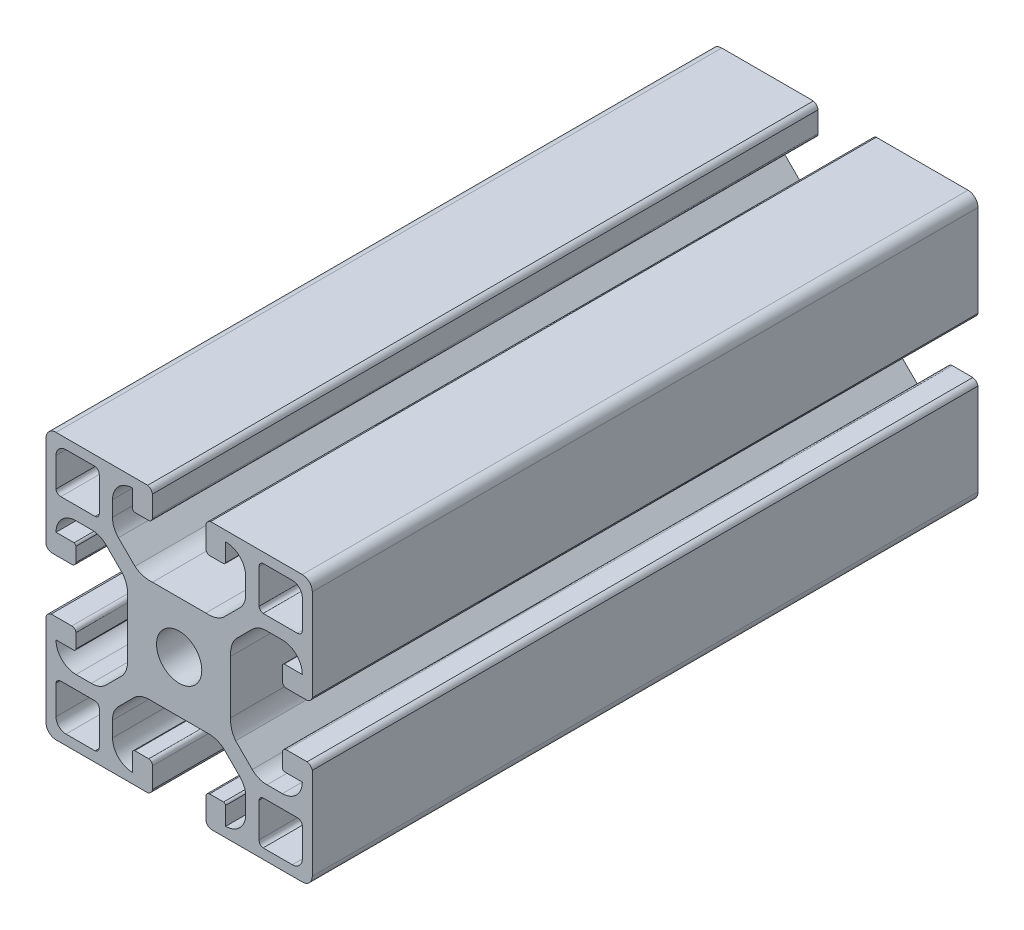
from build123d import *

# Parameters (mm, degrees)
CROQUIS1_R              = 3.4
SALIENTE_EXTRUIR1_DEPTH = 100


with BuildPart() as part:
    # Croquis1 → Saliente-Extruir1 (new body)
    with BuildSketch(Plane.XY):
        with BuildLine():
            ThreePointArc((1.5, 20), (0.439339828, 19.560660172), (0, 18.5))
            Line((0, 18.5), (0, 4.723246277))
            add(Edge.make_bspline(
                [(0, 4.723246277), (0.16818163, 4.15421854), (0.776519027, 4)],
                knots=[0, 0, 0, 1, 1, 1], degree=2))
            Line((0.776519027, 4), (3.876499959, 4))
            add(Edge.make_bspline(
                [(3.876499959, 4), (4.428343851, 4.075321958), (4.5, 4.561581647)],
                knots=[0, 0, 0, 0.770148696, 0.770148696, 0.770148696], degree=2))
            Line((4.5, 4.561581647), (4.5, 4.888433939))
            Line((4.5, 4.888433939), (4.5, 6.675480873))
            add(Edge.make_bspline(
                [(4.226708403, 7), (4.442584391, 6.908044465), (4.5, 6.675480873)],
                knots=[0, 0, 0, 1, 1, 1], degree=2))
            Line((4.226708403, 7), (1.5, 7))
            ThreePointArc((1.5, 7), (2.378679656, 9.121320344), (4.5, 10))
            Line((4.5, 10), (6.795713853, 10))
            add(Edge.make_bspline(
                [(6.795713853, 10), (6.864922078, 10.001348654), (6.933119616, 10)],
                knots=[0, 0, 0, 0.053884422, 0.053884422, 0.053884422], degree=2))
            add(Edge.make_bspline(
                [(6.933119616, 10), (8.130548293, 9.976320018), (9.016390221, 9.121082451)],
                knots=[0.053884422, 0.053884422, 0.053884422, 1, 1, 1], degree=2))
            Line((9.016390221, 9.121082451), (11.507582012, 6.629890661))
            add(Edge.make_bspline(
                [(11.507582012, 6.629890661), (12.156952743, 5.772287934), (12.25, 4.723246277)],
                knots=[0, 0, 0, 0.74933997, 0.74933997, 0.74933997], degree=2))
            add(Edge.make_bspline(
                [(12.25, 4.723246277), (12.281125029, 4.37233371), (12.25, 4)],
                knots=[0.74933997, 0.74933997, 0.74933997, 1, 1, 1], degree=2))
            Line((12.25, 4), (12.25, -4))
            add(Edge.make_bspline(
                [(12.25, -4.723246277), (12.281125029, -4.37233371), (12.25, -4)],
                knots=[0.74933997, 0.74933997, 0.74933997, 1, 1, 1], degree=2))
            add(Edge.make_bspline(
                [(11.507582012, -6.629890661), (12.156952743, -5.772287934), (12.25, -4.723246277)],
                knots=[0, 0, 0, 0.74933997, 0.74933997, 0.74933997], degree=2))
            Line((11.507582012, -6.629890661), (9.016390221, -9.121082451))
            add(Edge.make_bspline(
                [(6.933119616, -10), (8.130548293, -9.976320018), (9.016390221, -9.121082451)],
                knots=[0.053884422, 0.053884422, 0.053884422, 1, 1, 1], degree=2))
            add(Edge.make_bspline(
                [(6.795713853, -10), (6.864922078, -10.001348654), (6.933119616, -10)],
                knots=[0, 0, 0, 0.053884422, 0.053884422, 0.053884422], degree=2))
            Line((6.795713853, -10), (4.5, -10))
            ThreePointArc((4.5, -10), (2.378679656, -9.121320344), (1.5, -7))
            Line((1.5, -7), (4.226708403, -7))
            add(Edge.make_bspline(
                [(4.226708403, -7), (4.442584391, -6.908044465), (4.5, -6.675480873)],
                knots=[0, 0, 0, 1, 1, 1], degree=2))
            Line((4.5, -6.675480873), (4.5, -4.888433939))
            Line((4.5, -4.888433939), (4.5, -4.561581647))
            add(Edge.make_bspline(
                [(3.876499959, -4), (4.428343851, -4.075321958), (4.5, -4.561581647)],
                knots=[0, 0, 0, 0.770148696, 0.770148696, 0.770148696], degree=2))
            Line((3.876499959, -4), (0.776519027, -4))
            add(Edge.make_bspline(
                [(0, -4.723246277), (0.16818163, -4.15421854), (0.776519027, -4)],
                knots=[0, 0, 0, 1, 1, 1], degree=2))
            Line((0, -4.723246277), (0, -18.5))
            ThreePointArc((0, -18.5), (0.439339828, -19.560660172), (1.5, -20))
            Line((1.5, -20), (15.276753723, -20))
            add(Edge.make_bspline(
                [(15.276753723, -20), (15.84578146, -19.83181837), (16, -19.223480973)],
                knots=[0, 0, 0, 1, 1, 1], degree=2))
            Line((16, -19.223480973), (16, -16.123500041))
            add(Edge.make_bspline(
                [(16, -16.123500041), (15.924678042, -15.571656149), (15.438418353, -15.5)],
                knots=[0, 0, 0, 0.770148696, 0.770148696, 0.770148696], degree=2))
            Line((15.438418353, -15.5), (15.111566061, -15.5))
            Line((15.111566061, -15.5), (13.324519127, -15.5))
            add(Edge.make_bspline(
                [(13, -15.773291597), (13.091955535, -15.557415609), (13.324519127, -15.5)],
                knots=[0, 0, 0, 1, 1, 1], degree=2))
            Line((13, -15.773291597), (13, -18.5))
            ThreePointArc((13, -18.5), (10.878679656, -17.621320344), (10, -15.5))
            Line((10, -15.5), (10, -13.204286147))
            add(Edge.make_bspline(
                [(10, -13.204286147), (9.998651346, -13.135077922), (10, -13.066880384)],
                knots=[0, 0, 0, 0.053884422, 0.053884422, 0.053884422], degree=2))
            add(Edge.make_bspline(
                [(10, -13.066880384), (10.023679982, -11.869451707), (10.878917549, -10.983609779)],
                knots=[0.053884422, 0.053884422, 0.053884422, 1, 1, 1], degree=2))
            Line((10.878917549, -10.983609779), (13.370109339, -8.492417988))
            add(Edge.make_bspline(
                [(13.370109339, -8.492417988), (14.227712066, -7.843047257), (15.276753723, -7.75)],
                knots=[0, 0, 0, 0.74933997, 0.74933997, 0.74933997], degree=2))
            add(Edge.make_bspline(
                [(15.276753723, -7.75), (15.62766629, -7.718874971), (16, -7.75)],
                knots=[0.74933997, 0.74933997, 0.74933997, 1, 1, 1], degree=2))
            Line((16, -7.75), (24, -7.75))
            add(Edge.make_bspline(
                [(24.723246277, -7.75), (24.37233371, -7.718874971), (24, -7.75)],
                knots=[0.74933997, 0.74933997, 0.74933997, 1, 1, 1], degree=2))
            add(Edge.make_bspline(
                [(26.629890661, -8.492417988), (25.772287934, -7.843047257), (24.723246277, -7.75)],
                knots=[0, 0, 0, 0.74933997, 0.74933997, 0.74933997], degree=2))
            Line((26.629890661, -8.492417988), (29.121082451, -10.983609779))
            add(Edge.make_bspline(
                [(30, -13.066880384), (29.976320018, -11.869451707), (29.121082451, -10.983609779)],
                knots=[0.053884422, 0.053884422, 0.053884422, 1, 1, 1], degree=2))
            add(Edge.make_bspline(
                [(30, -13.204286147), (30.001348654, -13.135077922), (30, -13.066880384)],
                knots=[0, 0, 0, 0.053884422, 0.053884422, 0.053884422], degree=2))
            Line((30, -13.204286147), (30, -15.5))
            ThreePointArc((30, -15.5), (29.121320344, -17.621320344), (27, -18.5))
            Line((27, -18.5), (27, -15.773291597))
            add(Edge.make_bspline(
                [(27, -15.773291597), (26.908044465, -15.557415609), (26.675480873, -15.5)],
                knots=[0, 0, 0, 1, 1, 1], degree=2))
            Line((26.675480873, -15.5), (24.888433939, -15.5))
            Line((24.888433939, -15.5), (24.561581647, -15.5))
            add(Edge.make_bspline(
                [(24, -16.123500041), (24.075321958, -15.571656149), (24.561581647, -15.5)],
                knots=[0, 0, 0, 0.770148696, 0.770148696, 0.770148696], degree=2))
            Line((24, -16.123500041), (24, -19.223480973))
            add(Edge.make_bspline(
                [(24.723246277, -20), (24.15421854, -19.83181837), (24, -19.223480973)],
                knots=[0, 0, 0, 1, 1, 1], degree=2))
            Line((24.723246277, -20), (38.5, -20))
            ThreePointArc((38.5, -20), (39.560660172, -19.560660172), (40, -18.5))
            Line((40, -18.5), (40, -4.723246277))
            add(Edge.make_bspline(
                [(40, -4.723246277), (39.83181837, -4.15421854), (39.223480973, -4)],
                knots=[0, 0, 0, 1, 1, 1], degree=2))
            Line((39.223480973, -4), (36.123500041, -4))
            add(Edge.make_bspline(
                [(36.123500041, -4), (35.571656149, -4.075321958), (35.5, -4.561581647)],
                knots=[0, 0, 0, 0.770148696, 0.770148696, 0.770148696], degree=2))
            Line((35.5, -4.561581647), (35.5, -4.888433939))
            Line((35.5, -4.888433939), (35.5, -6.675480873))
            add(Edge.make_bspline(
                [(35.773291597, -7), (35.557415609, -6.908044465), (35.5, -6.675480873)],
                knots=[0, 0, 0, 1, 1, 1], degree=2))
            Line((35.773291597, -7), (38.5, -7))
            ThreePointArc((38.5, -7), (37.621320344, -9.121320344), (35.5, -10))
            Line((35.5, -10), (33.204286147, -10))
            add(Edge.make_bspline(
                [(33.204286147, -10), (33.135077922, -10.001348654), (33.066880384, -10)],
                knots=[0, 0, 0, 0.053884422, 0.053884422, 0.053884422], degree=2))
            add(Edge.make_bspline(
                [(33.066880384, -10), (31.869451707, -9.976320018), (30.983609779, -9.121082451)],
                knots=[0.053884422, 0.053884422, 0.053884422, 1, 1, 1], degree=2))
            Line((30.983609779, -9.121082451), (28.492417988, -6.629890661))
            add(Edge.make_bspline(
                [(28.492417988, -6.629890661), (27.843047257, -5.772287934), (27.75, -4.723246277)],
                knots=[0, 0, 0, 0.74933997, 0.74933997, 0.74933997], degree=2))
            add(Edge.make_bspline(
                [(27.75, -4.723246277), (27.718874971, -4.37233371), (27.75, -4)],
                knots=[0.74933997, 0.74933997, 0.74933997, 1, 1, 1], degree=2))
            Line((27.75, -4), (27.75, 4))
            add(Edge.make_bspline(
                [(27.75, 4.723246277), (27.718874971, 4.37233371), (27.75, 4)],
                knots=[0.74933997, 0.74933997, 0.74933997, 1, 1, 1], degree=2))
            add(Edge.make_bspline(
                [(28.492417988, 6.629890661), (27.843047257, 5.772287934), (27.75, 4.723246277)],
                knots=[0, 0, 0, 0.74933997, 0.74933997, 0.74933997], degree=2))
            Line((28.492417988, 6.629890661), (30.983609779, 9.121082451))
            add(Edge.make_bspline(
                [(33.066880384, 10), (31.869451707, 9.976320018), (30.983609779, 9.121082451)],
                knots=[0.053884422, 0.053884422, 0.053884422, 1, 1, 1], degree=2))
            add(Edge.make_bspline(
                [(33.204286147, 10), (33.135077922, 10.001348654), (33.066880384, 10)],
                knots=[0, 0, 0, 0.053884422, 0.053884422, 0.053884422], degree=2))
            Line((33.204286147, 10), (35.5, 10))
            ThreePointArc((35.5, 10), (37.621320344, 9.121320344), (38.5, 7))
            Line((38.5, 7), (35.773291597, 7))
            add(Edge.make_bspline(
                [(35.773291597, 7), (35.557415609, 6.908044465), (35.5, 6.675480873)],
                knots=[0, 0, 0, 1, 1, 1], degree=2))
            Line((35.5, 6.675480873), (35.5, 4.888433939))
            Line((35.5, 4.888433939), (35.5, 4.561581647))
            add(Edge.make_bspline(
                [(36.123500041, 4), (35.571656149, 4.075321958), (35.5, 4.561581647)],
                knots=[0, 0, 0, 0.770148696, 0.770148696, 0.770148696], degree=2))
            Line((36.123500041, 4), (39.223480973, 4))
            add(Edge.make_bspline(
                [(40, 4.723246277), (39.83181837, 4.15421854), (39.223480973, 4)],
                knots=[0, 0, 0, 1, 1, 1], degree=2))
            Line((40, 4.723246277), (40, 18.5))
            ThreePointArc((40, 18.5), (39.560660172, 19.560660172), (38.5, 20))
            Line((38.5, 20), (24.723246277, 20))
            add(Edge.make_bspline(
                [(24.723246277, 20), (24.15421854, 19.83181837), (24, 19.223480973)],
                knots=[0, 0, 0, 1, 1, 1], degree=2))
            Line((24, 19.223480973), (24, 16.123500041))
            add(Edge.make_bspline(
                [(24, 16.123500041), (24.075321958, 15.571656149), (24.561581647, 15.5)],
                knots=[0, 0, 0, 0.770148696, 0.770148696, 0.770148696], degree=2))
            Line((24.561581647, 15.5), (24.888433939, 15.5))
            Line((24.888433939, 15.5), (26.675480873, 15.5))
            add(Edge.make_bspline(
                [(27, 15.773291597), (26.908044465, 15.557415609), (26.675480873, 15.5)],
                knots=[0, 0, 0, 1, 1, 1], degree=2))
            Line((27, 15.773291597), (27, 18.5))
            ThreePointArc((27, 18.5), (29.121320344, 17.621320344), (30, 15.5))
            Line((30, 15.5), (30, 13.204286147))
            add(Edge.make_bspline(
                [(30, 13.204286147), (30.001348654, 13.135077922), (30, 13.066880384)],
                knots=[0, 0, 0, 0.053884422, 0.053884422, 0.053884422], degree=2))
            add(Edge.make_bspline(
                [(30, 13.066880384), (29.976320018, 11.869451707), (29.121082451, 10.983609779)],
                knots=[0.053884422, 0.053884422, 0.053884422, 1, 1, 1], degree=2))
            Line((29.121082451, 10.983609779), (26.629890661, 8.492417988))
            add(Edge.make_bspline(
                [(26.629890661, 8.492417988), (25.772287934, 7.843047257), (24.723246277, 7.75)],
                knots=[0, 0, 0, 0.74933997, 0.74933997, 0.74933997], degree=2))
            add(Edge.make_bspline(
                [(24.723246277, 7.75), (24.37233371, 7.718874971), (24, 7.75)],
                knots=[0.74933997, 0.74933997, 0.74933997, 1, 1, 1], degree=2))
            Line((24, 7.75), (16, 7.75))
            add(Edge.make_bspline(
                [(15.276753723, 7.75), (15.62766629, 7.718874971), (16, 7.75)],
                knots=[0.74933997, 0.74933997, 0.74933997, 1, 1, 1], degree=2))
            add(Edge.make_bspline(
                [(13.370109339, 8.492417988), (14.227712066, 7.843047257), (15.276753723, 7.75)],
                knots=[0, 0, 0, 0.74933997, 0.74933997, 0.74933997], degree=2))
            Line((13.370109339, 8.492417988), (10.878917549, 10.983609779))
            add(Edge.make_bspline(
                [(10, 13.066880384), (10.023679982, 11.869451707), (10.878917549, 10.983609779)],
                knots=[0.053884422, 0.053884422, 0.053884422, 1, 1, 1], degree=2))
            add(Edge.make_bspline(
                [(10, 13.204286147), (9.998651346, 13.135077922), (10, 13.066880384)],
                knots=[0, 0, 0, 0.053884422, 0.053884422, 0.053884422], degree=2))
            Line((10, 13.204286147), (10, 15.5))
            ThreePointArc((10, 15.5), (10.878679656, 17.621320344), (13, 18.5))
            Line((13, 18.5), (13, 15.773291597))
            add(Edge.make_bspline(
                [(13, 15.773291597), (13.091955535, 15.557415609), (13.324519127, 15.5)],
                knots=[0, 0, 0, 1, 1, 1], degree=2))
            Line((13.324519127, 15.5), (15.111566061, 15.5))
            Line((15.111566061, 15.5), (15.438418353, 15.5))
            add(Edge.make_bspline(
                [(16, 16.123500041), (15.924678042, 15.571656149), (15.438418353, 15.5)],
                knots=[0, 0, 0, 0.770148696, 0.770148696, 0.770148696], degree=2))
            Line((16, 16.123500041), (16, 19.223480973))
            add(Edge.make_bspline(
                [(15.276753723, 20), (15.84578146, 19.83181837), (16, 19.223480973)],
                knots=[0, 0, 0, 1, 1, 1], degree=2))
            Line((15.276753723, 20), (1.5, 20))
        make_face()
        with BuildLine():
            add(Edge.make_bspline(
                [(7.381658877, -18.5), (7.954867262, -18.386704516), (8, -17.770035709)],
                knots=[0, 0, 0, 1, 1, 1], degree=2))
            Line((7.381658877, -18.5), (3, -18.5))
            ThreePointArc((3, -18.5), (1.939339828, -18.060660172), (1.5, -17))
            Line((1.5, -17), (1.5, -12.618341123))
            add(Edge.make_bspline(
                [(1.5, -12.618341123), (1.613295484, -12.045132738), (2.229964291, -12)],
                knots=[0, 0, 0, 1, 1, 1], degree=2))
            Line((2.229964291, -12), (5.716559808, -12))
            Line((5.716559808, -12), (7.381658877, -12))
            add(Edge.make_bspline(
                [(7.381658877, -12), (7.910058331, -12.07521512), (8, -12.618341123)],
                knots=[0, 0, 0, 1, 1, 1], degree=2))
            Line((8, -12.618341123), (8, -14.283440192))
            Line((8, -14.283440192), (8, -17.770035709))
        make_face(mode=Mode.SUBTRACT)
        with BuildLine():
            Line((32.618341123, -12), (34.283440192, -12))
            Line((34.283440192, -12), (37.770035709, -12))
            add(Edge.make_bspline(
                [(38.5, -12.618341123), (38.386704516, -12.045132738), (37.770035709, -12)],
                knots=[0, 0, 0, 1, 1, 1], degree=2))
            Line((38.5, -12.618341123), (38.5, -17))
            ThreePointArc((38.5, -17), (38.060660172, -18.060660172), (37, -18.5))
            Line((37, -18.5), (32.618341123, -18.5))
            add(Edge.make_bspline(
                [(32.618341123, -18.5), (32.045132738, -18.386704516), (32, -17.770035709)],
                knots=[0, 0, 0, 1, 1, 1], degree=2))
            Line((32, -17.770035709), (32, -14.283440192))
            Line((32, -14.283440192), (32, -12.618341123))
            add(Edge.make_bspline(
                [(32.618341123, -12), (32.089941669, -12.07521512), (32, -12.618341123)],
                knots=[0, 0, 0, 1, 1, 1], degree=2))
        make_face(mode=Mode.SUBTRACT)
        with Locations((20, 0)):
            Circle(CROQUIS1_R, mode=Mode.SUBTRACT)
        with BuildLine():
            Line((7.381658877, 12), (5.716559808, 12))
            Line((5.716559808, 12), (2.229964291, 12))
            add(Edge.make_bspline(
                [(1.5, 12.618341123), (1.613295484, 12.045132738), (2.229964291, 12)],
                knots=[0, 0, 0, 1, 1, 1], degree=2))
            Line((1.5, 12.618341123), (1.5, 17))
            ThreePointArc((1.5, 17), (1.939339828, 18.060660172), (3, 18.5))
            Line((3, 18.5), (7.381658877, 18.5))
            add(Edge.make_bspline(
                [(7.381658877, 18.5), (7.954867262, 18.386704516), (8, 17.770035709)],
                knots=[0, 0, 0, 1, 1, 1], degree=2))
            Line((8, 17.770035709), (8, 14.283440192))
            Line((8, 14.283440192), (8, 12.618341123))
            add(Edge.make_bspline(
                [(7.381658877, 12), (7.910058331, 12.07521512), (8, 12.618341123)],
                knots=[0, 0, 0, 1, 1, 1], degree=2))
        make_face(mode=Mode.SUBTRACT)
        with BuildLine():
            add(Edge.make_bspline(
                [(32.618341123, 18.5), (32.045132738, 18.386704516), (32, 17.770035709)],
                knots=[0, 0, 0, 1, 1, 1], degree=2))
            Line((32.618341123, 18.5), (37, 18.5))
            ThreePointArc((37, 18.5), (38.060660172, 18.060660172), (38.5, 17))
            Line((38.5, 17), (38.5, 12.618341123))
            add(Edge.make_bspline(
                [(38.5, 12.618341123), (38.386704516, 12.045132738), (37.770035709, 12)],
                knots=[0, 0, 0, 1, 1, 1], degree=2))
            Line((37.770035709, 12), (34.283440192, 12))
            Line((34.283440192, 12), (32.618341123, 12))
            add(Edge.make_bspline(
                [(32.618341123, 12), (32.089941669, 12.07521512), (32, 12.618341123)],
                knots=[0, 0, 0, 1, 1, 1], degree=2))
            Line((32, 12.618341123), (32, 14.283440192))
            Line((32, 14.283440192), (32, 17.770035709))
        make_face(mode=Mode.SUBTRACT)
    extrude(amount=SALIENTE_EXTRUIR1_DEPTH)


solid = part.part
